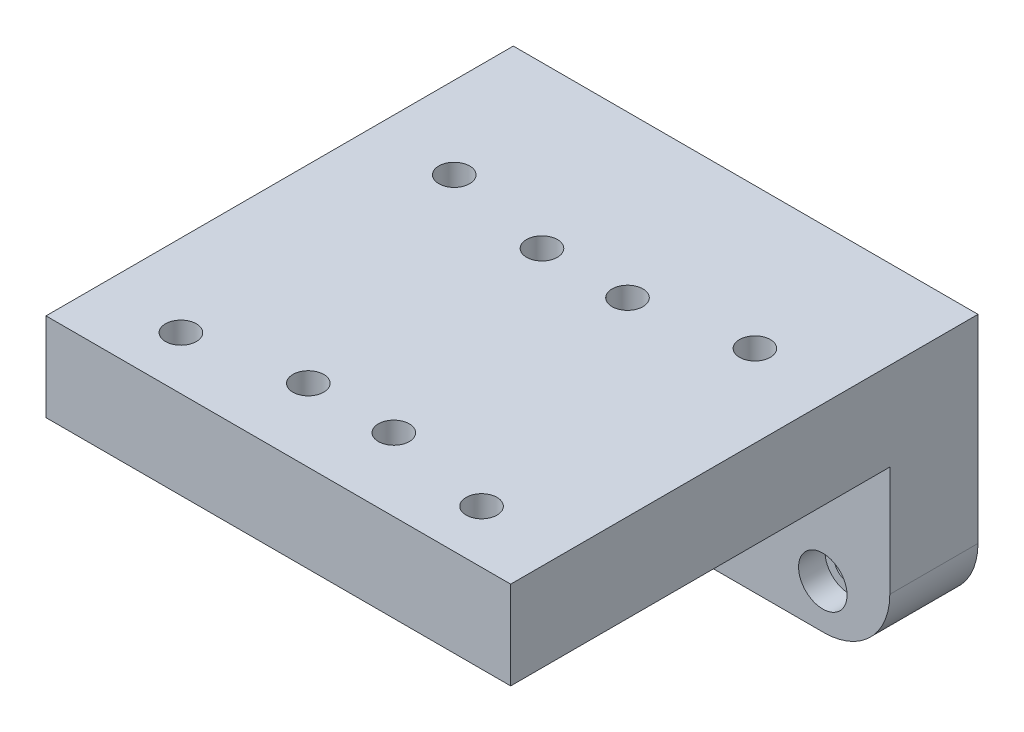
from build123d import *

# Parameters (mm, degrees)
SKETCH1_W                                  = 95.4
SKETCH1_H                                  = 76
BOSS_EXTRUDE1_DEPTH                        = 13
SKETCH2_R                                  = 3.5
CUT_EXTRUDE1_DEPTH                         = 63.356154468
MIRROR1_AT_THE_SECOND_PLANE_COPY_1_SKETC_R = 3.5
MIRROR1_AT_THE_SECOND_PLANE_COPY_1_DEPTH   = 63.356154468
SKETCH3_W                                  = 105.4
SKETCH3_H                                  = 86
SKETCH3_W_2                                = 95.4
SKETCH3_H_2                                = 76
BOSS_EXTRUDE2_DEPTH                        = 20
SKETCH3_4_W                                = 105.4
SKETCH3_4_H                                = 20
BOSS_EXTRUDE3_DEPTH                        = 60
CBORE_FOR_M6_SHCS1_D                       = 7
CBORE_FOR_M6_SHCS1_CBORE_D                 = 11
CBORE_FOR_M6_SHCS1_CBORE_DEPTH             = 6
FILLET1_R                                  = 15


with BuildPart() as part:
    # Sketch1 → Boss-Extrude1 (new body)
    with BuildSketch(Plane(origin=(0, 0, 0), x_dir=(1, 0, 0), z_dir=(0, 1, 0))):
        Rectangle(SKETCH1_W, SKETCH1_H)
    extrude(amount=BOSS_EXTRUDE1_DEPTH)

    # Sketch2 → Cut-Extrude1 (cut, through all)
    with BuildSketch(Plane(origin=(0, 13, 0), x_dir=(1, 0, 0), z_dir=(0, 1, 0))):
        with Locations((-34.1, 31)):
            Circle(SKETCH2_R)
        with Locations((-9.7, 26.5)):
            Circle(SKETCH2_R)
    cut_extrude1 = extrude(amount=-CUT_EXTRUDE1_DEPTH, mode=Mode.SUBTRACT)

    # Mirror1: Cut-Extrude1 across plane
    add(cut_extrude1.mirror(Plane(origin=(0, 0, 0), x_dir=(0, 0, 1), z_dir=(1, 0, 0))), mode=Mode.SUBTRACT)

    # Mirror1 at the second plane: Cut-Extrude1 across plane
    add(cut_extrude1.mirror(Plane.XY), mode=Mode.SUBTRACT)

    # Mirror1 at the second plane copy 1 sketc → Mirror1 at the second plane copy 1 (cut, through all)
    with BuildSketch(Plane(origin=(0, 13, 0), x_dir=(-1, 0, 0), z_dir=(0, 1, 0))):
        with Locations((-34.1, 31)):
            Circle(MIRROR1_AT_THE_SECOND_PLANE_COPY_1_SKETC_R)
        with Locations((-9.7, 26.5)):
            Circle(MIRROR1_AT_THE_SECOND_PLANE_COPY_1_SKETC_R)
    extrude(amount=-MIRROR1_AT_THE_SECOND_PLANE_COPY_1_DEPTH, mode=Mode.SUBTRACT)

    # Sketch3 → Boss-Extrude2 (add)
    with BuildSketch(Plane(origin=(0, 13, 0), x_dir=(1, 0, 0), z_dir=(0, 1, 0))):
        Rectangle(SKETCH3_W, SKETCH3_H)
        Rectangle(SKETCH3_W_2, SKETCH3_H_2, mode=Mode.SUBTRACT)
    extrude(amount=-BOSS_EXTRUDE2_DEPTH)

    # Sketch3_4 → Boss-Extrude3 (add)
    with BuildSketch(Plane(origin=(0, 13, 0), x_dir=(1, 0, 0), z_dir=(0, 1, 0))):
        with Locations((0, 53)):
            Rectangle(SKETCH3_4_W, SKETCH3_4_H)
    extrude(amount=-BOSS_EXTRUDE3_DEPTH)

    # CBORE for M6 SHCS1 (through all)
    with Locations(Plane(origin=(37.5, -37, -43), x_dir=(1, 0, 0), z_dir=(0, 0, 1))):
        with Locations((0, 0), (-75, 0)):
            CounterBoreHole(CBORE_FOR_M6_SHCS1_D / 2, CBORE_FOR_M6_SHCS1_CBORE_D / 2, CBORE_FOR_M6_SHCS1_CBORE_DEPTH)

    # Fillet1
    fillet1_edges = [part.edges().sort_by_distance(p)[0] for p in [
        (-52.7, -47, -53),
        (52.7, -47, -53),
    ]]
    fillet(fillet1_edges, radius=FILLET1_R)


solid = part.part
